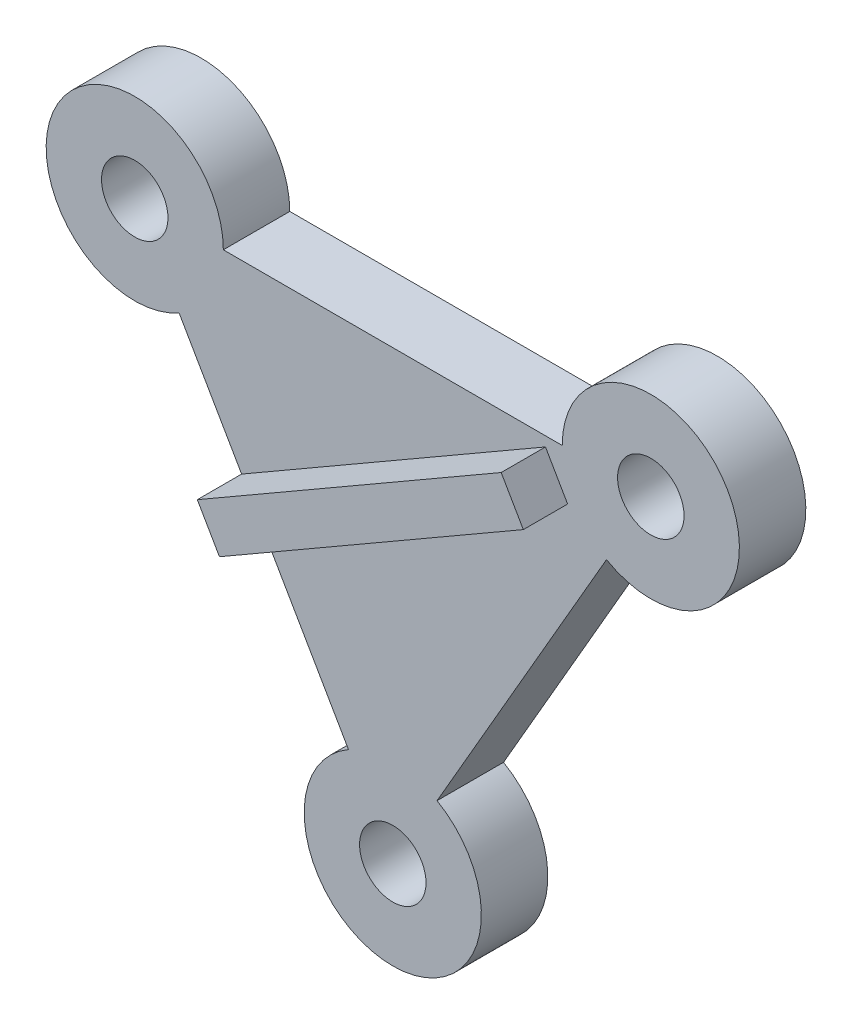
from build123d import *

# Parameters (mm, degrees)
BODY_R          = 1.5
MAIN_BODY_DEPTH = 3
FIT_DEPTH       = 2


with BuildPart() as part:
    # body → main-body (new body)
    with BuildSketch(Plane.XY):
        with BuildLine():
            Line((-13.783032013, 30.826495293), (1.516967987, 30.826495293))
            ThreePointArc((1.516967987, 30.826495293), (8.981069602, 32.826495293), (3.516967987, 27.362393677))
            Line((3.516967987, 27.362393677), (-4.133032013, 14.112205))
            ThreePointArc((-4.133032013, 14.112205), (-6.133032013, 6.648103384), (-8.133032013, 14.112205))
            Line((-8.133032013, 14.112205), (-15.783032013, 27.362393677))
            ThreePointArc((-15.783032013, 27.362393677), (-21.247133628, 32.826495293), (-13.783032013, 30.826495293))
        make_face()
        with Locations((-17.783032013, 30.826495293)):
            Circle(BODY_R, mode=Mode.SUBTRACT)
        with Locations((5.516967987, 30.826495293)):
            Circle(BODY_R, mode=Mode.SUBTRACT)
        with Locations((-6.133032013, 10.648103384)):
            Circle(BODY_R, mode=Mode.SUBTRACT)
    extrude(amount=MAIN_BODY_DEPTH)

    # Skizze3 → fit (add)
    with BuildSketch(Plane.XY.offset(3)):
        Polygon((-11.958032013, 20.737299339), (-12.958032013, 22.469350146), (0.760919419, 30.389990449), (1.760919419, 28.657939641), align=None)
    extrude(amount=FIT_DEPTH)


solid = part.part
